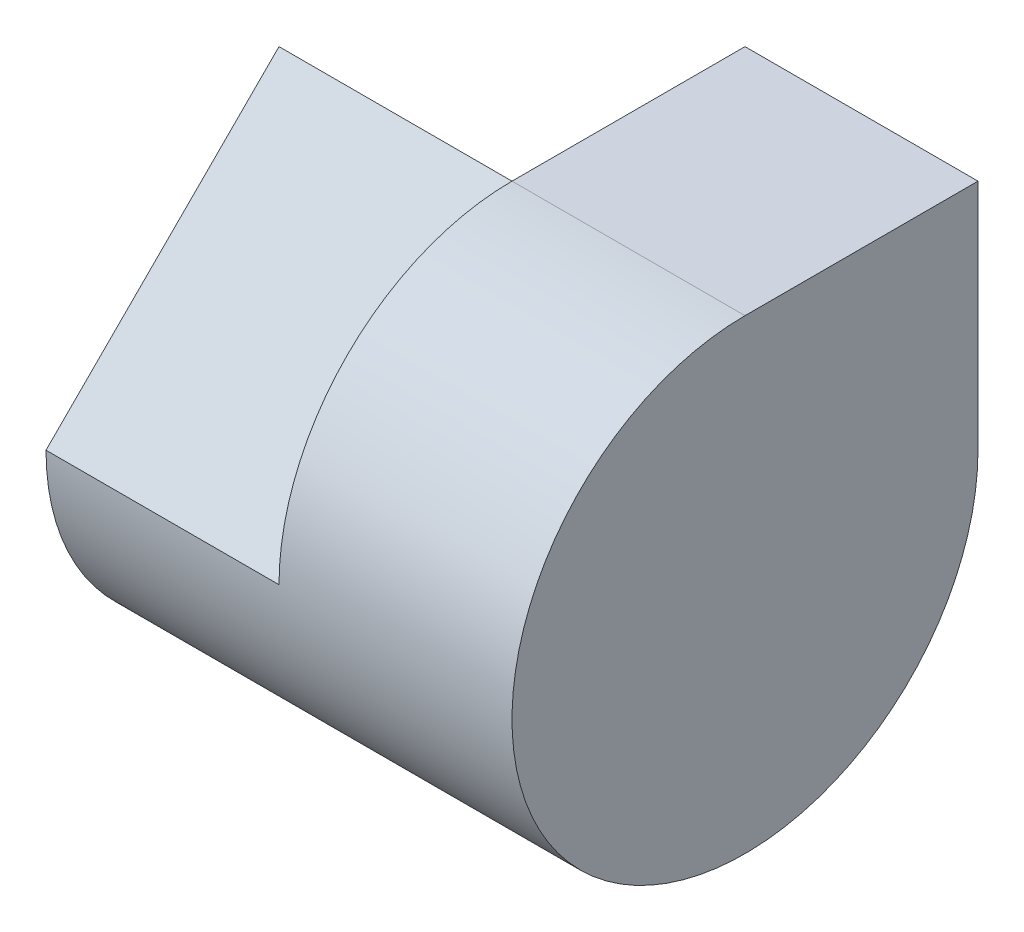
from build123d import *

# Parameters (mm, degrees)
SKETCH1_W           = 4
SKETCH1_H           = 4
BOSS_EXTRUDE1_DEPTH = 4
SKETCH2_W           = 2
SKETCH2_H           = 2
CUT_EXTRUDE1_DEPTH  = 2
CUT_EXTRUDE2_DEPTH  = 20


with BuildPart() as part:
    # Sketch1 → Boss-Extrude1 (new body)
    with BuildSketch(Plane(origin=(0, 0, 0), x_dir=(1, 0, 0), z_dir=(0, 1, 0))):
        Rectangle(SKETCH1_W, SKETCH1_H)
    extrude(amount=BOSS_EXTRUDE1_DEPTH)

    # Sketch2 → Cut-Extrude1 (cut)
    with BuildSketch(Plane.ZY.offset(2)):
        Polygon((0, 4), (2, 2), (2, 4), align=None)
        with Locations((-1, 3)):
            Rectangle(SKETCH2_W, SKETCH2_H)
    extrude(amount=-CUT_EXTRUDE1_DEPTH, mode=Mode.SUBTRACT)

    # Sketch3 → Cut-Extrude2 (cut, symmetric)
    with BuildSketch(Plane.ZY):
        with BuildLine():
            Line((2, 4), (0, 4))
            ThreePointArc((0, 4), (1.414213562, 3.414213562), (2, 2))
            Line((2, 2), (2, 4))
        make_face()
        with BuildLine():
            Line((2, 0), (2, 2))
            ThreePointArc((2, 2), (1.414213562, 0.585786438), (0, 0))
            Line((0, 0), (2, 0))
        make_face()
        with BuildLine():
            Line((-2, 0), (0, 0))
            ThreePointArc((0, 0), (-1.414213562, 0.585786438), (-2, 2))
            Line((-2, 2), (-2, 0))
        make_face()
    extrude(amount=CUT_EXTRUDE2_DEPTH, both=True, mode=Mode.SUBTRACT)


solid = part.part
